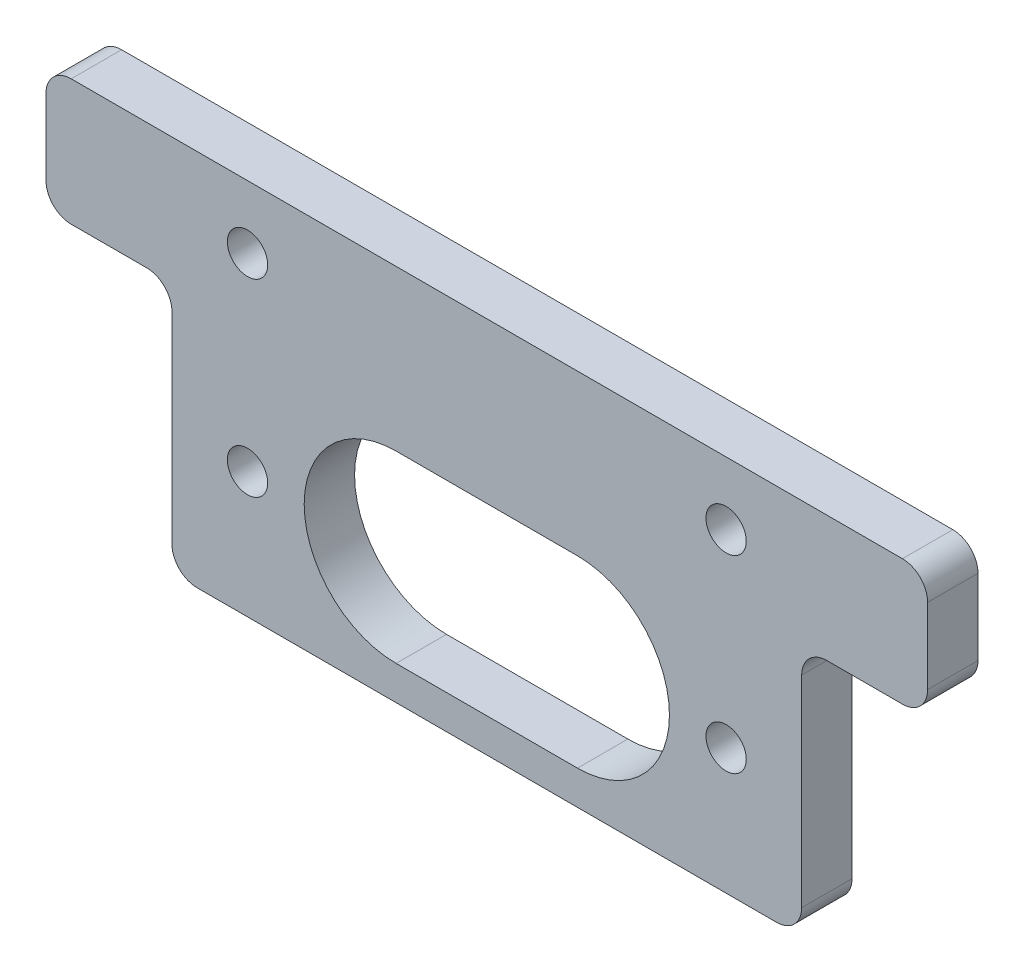
from build123d import *

# Parameters (mm, degrees)
EXTRUDE_1_DEPTH     = 4
SKETCH_2_R          = 1.6
CUT_EXTRUDE_1_DEPTH = 5
CUT_EXTRUDE_2_DEPTH = 5
FILLET_1_R          = 2


with BuildPart() as part:
    # 草图1 → 凸台-拉伸1 (new body)
    with BuildSketch(Plane.XY):
        Polygon((-25, 0), (25, 0), (25, 20), (35, 20), (35, 30), (-35, 30), (-35, 20), (-25, 20), align=None)
    extrude(amount=EXTRUDE_1_DEPTH)

    # 草图2 → 切除-拉伸1 (cut, through all)
    with BuildSketch(Plane.XY.offset(4)):
        with Locations((19, 10)):
            Circle(SKETCH_2_R)
        with Locations((19, 25)):
            Circle(SKETCH_2_R)
        with Locations((-19, 10)):
            Circle(SKETCH_2_R)
        with Locations((-19, 25)):
            Circle(SKETCH_2_R)
    extrude(amount=-CUT_EXTRUDE_1_DEPTH, mode=Mode.SUBTRACT)

    # 草图3 → 切除-拉伸2 (cut, through all)
    with BuildSketch(Plane.XY.offset(4)):
        with BuildLine():
            Line((-7.2, 17.3), (7.2, 17.3))
            ThreePointArc((7.2, 17.3), (14.5, 10), (7.2, 2.7))
            Line((7.2, 2.7), (-7.2, 2.7))
            ThreePointArc((-7.2, 2.7), (-14.5, 10), (-7.2, 17.3))
        make_face()
    extrude(amount=-CUT_EXTRUDE_2_DEPTH, mode=Mode.SUBTRACT)

    # 圆角1
    fillet_1_edges = [part.edges().sort_by_distance(p)[0] for p in [
        (-25, 20, 2),
        (-35, 20, 2),
        (-35, 30, 2),
        (35, 30, 2),
        (35, 20, 2),
        (25, 20, 2),
        (25, 0, 2),
        (-25, 0, 2),
    ]]
    fillet(fillet_1_edges, radius=FILLET_1_R)


solid = part.part
